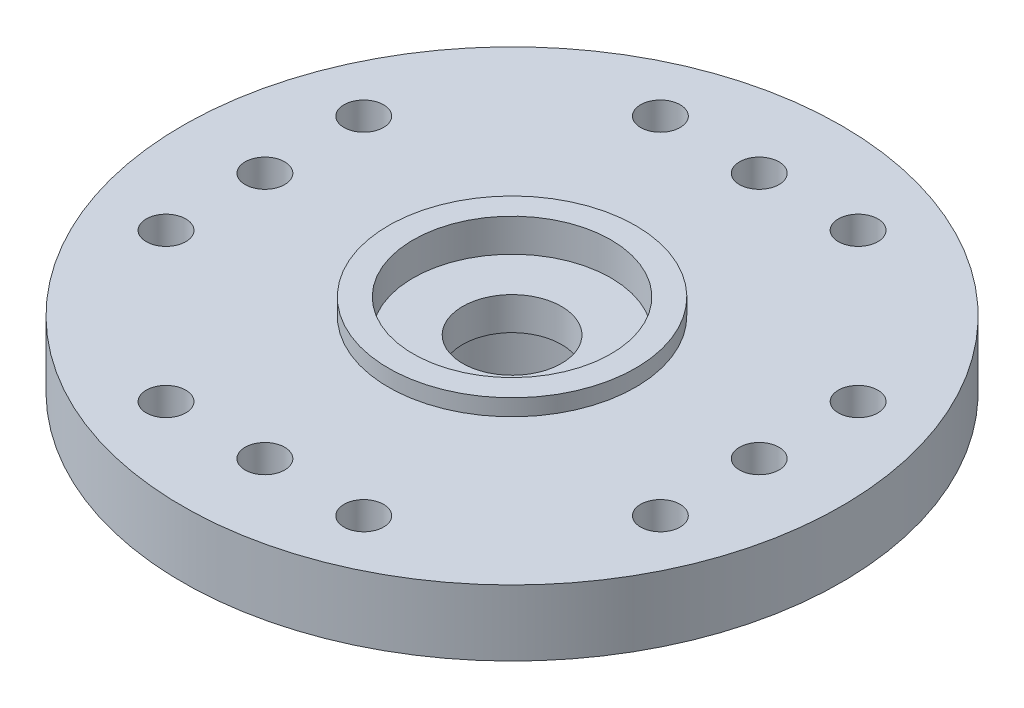
from build123d import *

# Parameters (mm, degrees)
SKETCH1_R          = 0.6
CUT_EXTRUDE1_DEPTH = 2
CIRPATTERN1_COUNT  = 4


with BuildPart() as part:
    # Esquisse1 → Révolution1 (revolve)
    with BuildSketch(Plane.XY):
        Polygon((2.75, 0), (2.75, 3), (1.5, 3), (1.5, 4), (3, 4), (3, 5), (3.75, 5), (3.75, 4.5), (10, 4.5), (10, 2.5), (4.5, 2.5), (4.5, 0), align=None)
    revolve(axis=Axis((0, 0, 0), (0, 1, 0)))

    # Sketch1 → Cut-Extrude1 (cut)
    with BuildSketch(Plane(origin=(0, 4.5, 0), x_dir=(1, 0, 0), z_dir=(0, 1, 0))):
        with Locations((0, 7.5)):
            Circle(SKETCH1_R)
        with Locations((3, 7.5)):
            Circle(SKETCH1_R)
        with Locations((-3, 7.5)):
            Circle(SKETCH1_R)
    cut_extrude1 = extrude(amount=-CUT_EXTRUDE1_DEPTH, mode=Mode.SUBTRACT)

    # CirPattern1: Cut-Extrude1 ×4 about axis
    cirpattern1_axis = Axis((0, 0, 0), (0, 1, 0))
    for i in range(1, CIRPATTERN1_COUNT):
        add(cut_extrude1.rotate(cirpattern1_axis, i * 360 / CIRPATTERN1_COUNT), mode=Mode.SUBTRACT)


solid = part.part
